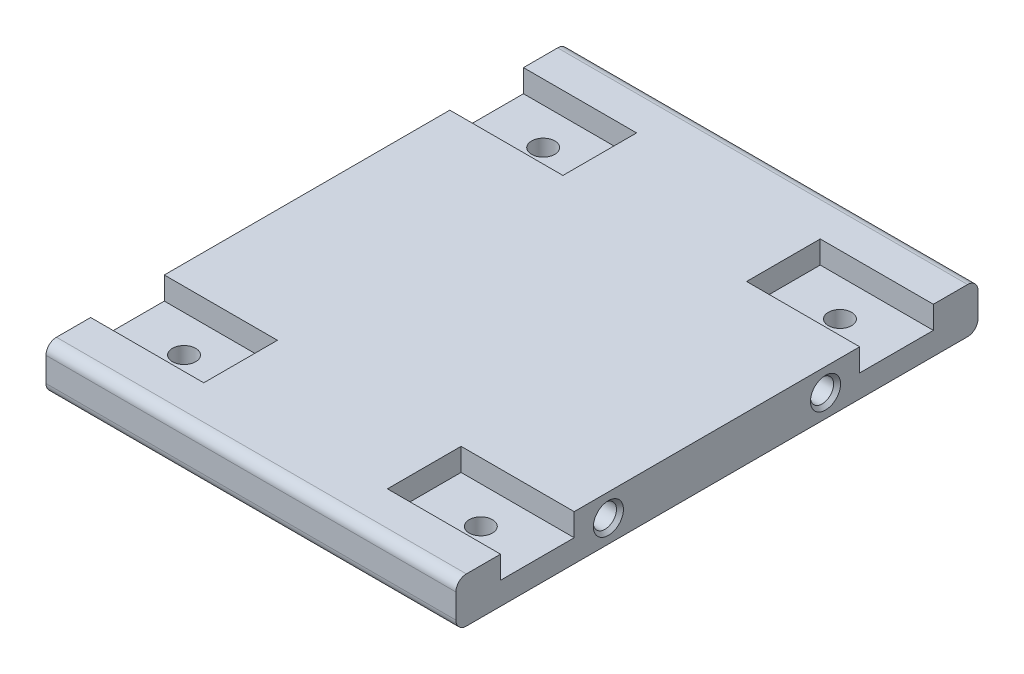
from build123d import *

# Parameters (mm, degrees)
SKETCH1_W           = 117.7655389
SKETCH1_H           = 150
BOSS_EXTRUDE1_DEPTH = 13
FILLET1_R           = 3
SKETCH2_W           = 21.16486665
SKETCH2_H           = 6.5
CUT_EXTRUDE1_DEPTH  = 32.5
SKETCH3_R           = 3.35
CUT_EXTRUDE2_DEPTH  = 6.5
SKETCH4_R           = 3.325
CUT_EXTRUDE3_DEPTH  = 117.765539
CHAMFER1_SIZE       = 1


with BuildPart() as part:
    # Sketch1 → Boss-Extrude1 (new body)
    with BuildSketch(Plane(origin=(0, 0, 0), x_dir=(1, 0, 0), z_dir=(0, 1, 0))):
        Rectangle(SKETCH1_W, SKETCH1_H)
    extrude(amount=BOSS_EXTRUDE1_DEPTH)

    # Fillet1
    fillet1_edges = [part.edges().sort_by_distance(p)[0] for p in [
        (0, 13, 75),
        (0, 0, 75),
        (0, 0, -75),
        (0, 13, -75),
    ]]
    fillet(fillet1_edges, radius=FILLET1_R)

    # Sketch2 → Cut-Extrude1 (cut)
    with BuildSketch(Plane.ZY.offset(58.88276945)):
        with Locations((-51.59450088, 9.75)):
            Rectangle(SKETCH2_W, SKETCH2_H)
        with Locations((51.59450088, 9.75)):
            Rectangle(SKETCH2_W, SKETCH2_H)
    cut_extrude1 = extrude(amount=-CUT_EXTRUDE1_DEPTH, mode=Mode.SUBTRACT)

    # Sketch3 → Cut-Extrude2 (cut)
    with BuildSketch(Plane(origin=(0, 6.5, 0), x_dir=(1, 0, 0), z_dir=(0, 1, 0))):
        with Locations((-42.63276945, 51.59450088)):
            Circle(SKETCH3_R)
        with Locations((-42.63276945, -51.59450088)):
            Circle(SKETCH3_R)
    cut_extrude2 = extrude(amount=-CUT_EXTRUDE2_DEPTH, mode=Mode.SUBTRACT)

    # Mirror1: Cut-Extrude1, Cut-Extrude2 across plane
    add(cut_extrude1.mirror(Plane(origin=(0, 0, 0), x_dir=(0, 0, 1), z_dir=(1, 0, 0))), mode=Mode.SUBTRACT)
    add(cut_extrude2.mirror(Plane(origin=(0, 0, 0), x_dir=(0, 0, 1), z_dir=(1, 0, 0))), mode=Mode.SUBTRACT)

    # Sketch4 → Cut-Extrude3 (cut)
    with BuildSketch(Plane.ZY.offset(58.88276945)):
        with Locations((31.18900176, 6.5)):
            Circle(SKETCH4_R)
        with Locations((-31.18900176, 6.5)):
            Circle(SKETCH4_R)
    extrude(amount=-CUT_EXTRUDE3_DEPTH, mode=Mode.SUBTRACT)

    # Chamfer1
    chamfer1_edges = [part.edges().sort_by_distance(p)[0] for p in [
        (-58.88276945, 6.5, 27.86400176),
        (58.88276955, 6.5, 27.86400176),
        (-58.88276945, 6.5, -34.51400176),
        (58.88276955, 6.5, -34.51400176),
    ]]
    chamfer(chamfer1_edges, length=CHAMFER1_SIZE)


solid = part.part
